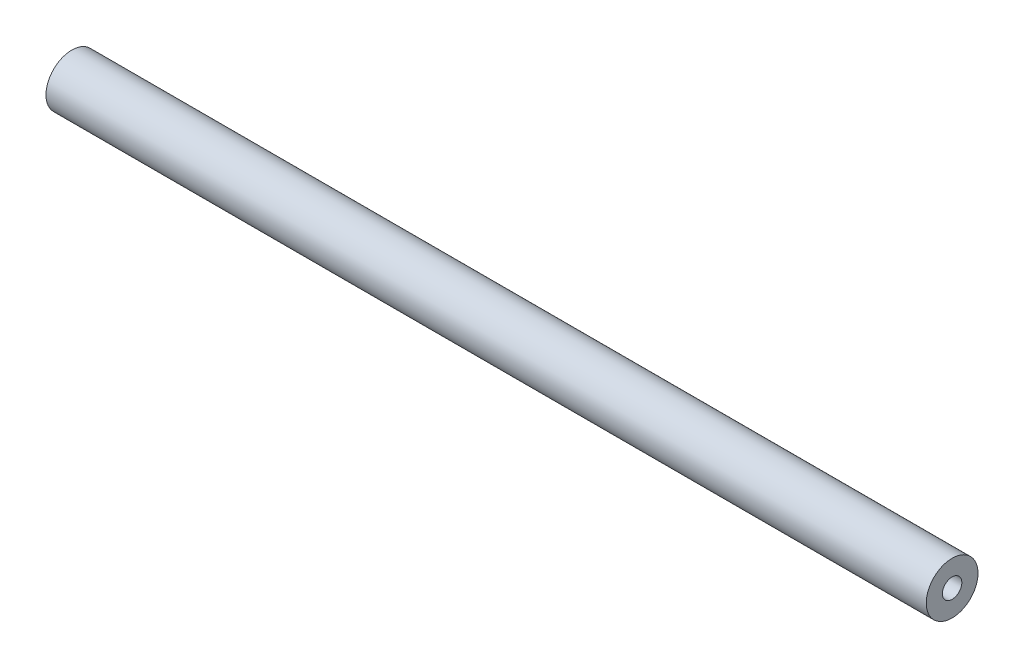
from build123d import *

# Parameters (mm, degrees)
SKETCH_1_W          = 136
SKETCH_1_H          = 8
EXTRUDE_1_DEPTH     = 8
SKETCH_2_R          = 1.5
CUT_EXTRUDE_1_DEPTH = 10
CUT_EXTRUDE_START   = -126
SKETCH_2_2_R        = 1.5
CUT_EXTRUDE_2_DEPTH = 10
SKETCH_3_R          = 6
SKETCH_3_R_2        = 4
CUT_EXTRUDE_3_DEPTH = 137.469776874


with BuildPart() as part:
    # 草图1 → 凸台-拉伸1 (new body)
    with BuildSketch(Plane.XY):
        with Locations((68, -4)):
            Rectangle(SKETCH_1_W, SKETCH_1_H)
    extrude(amount=EXTRUDE_1_DEPTH)

    # 草图2 → 切除-拉伸1 (cut)
    with BuildSketch(Plane.ZY):
        with Locations((4, -4)):
            Circle(SKETCH_2_R)
    extrude(amount=-CUT_EXTRUDE_1_DEPTH, mode=Mode.SUBTRACT)

    # 草图2<2> → 切除-拉伸2 (cut)
    with BuildSketch(Plane.ZY.offset(CUT_EXTRUDE_START)):
        with Locations((4, -4)):
            Circle(SKETCH_2_2_R)
    extrude(amount=-CUT_EXTRUDE_2_DEPTH, mode=Mode.SUBTRACT)

    # 草图3 → 切除-拉伸3 (cut, through all)
    with BuildSketch(Plane(origin=(136, 0, 0), x_dir=(0, 0, -1), z_dir=(1, 0, 0))):
        with Locations((-4, -4)):
            Circle(SKETCH_3_R)
        with Locations((-4, -4)):
            Circle(SKETCH_3_R_2, mode=Mode.SUBTRACT)
    extrude(amount=-CUT_EXTRUDE_3_DEPTH, mode=Mode.SUBTRACT)


solid = part.part
